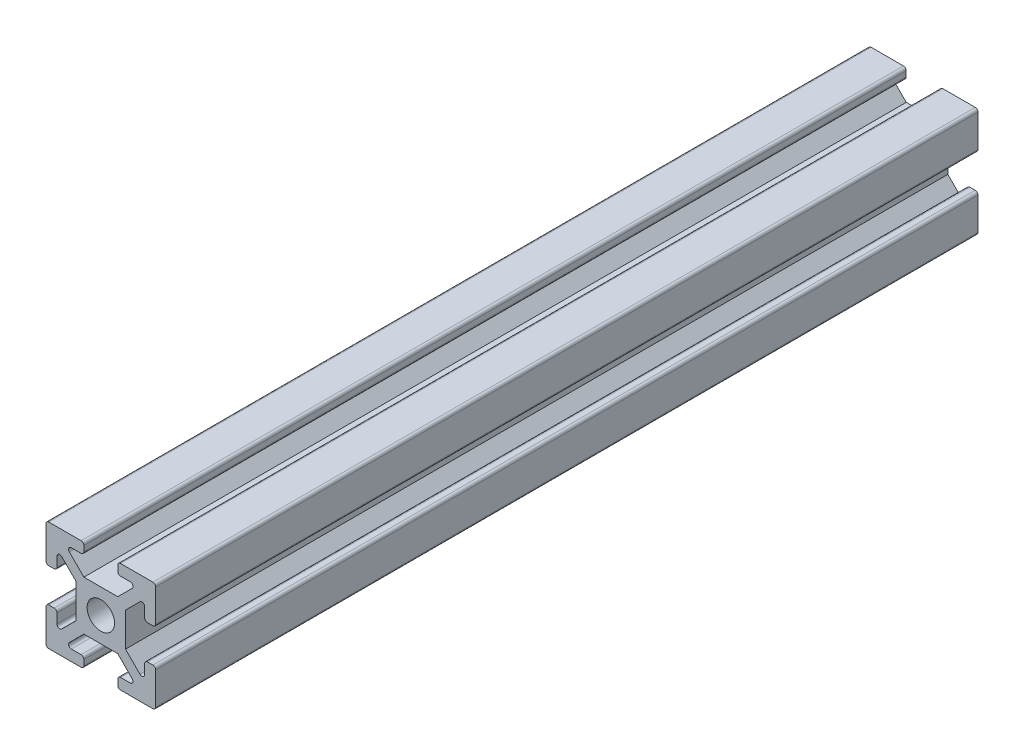
from build123d import *

# Parameters (mm, degrees)
AUFSATZ_LINEAR_AUSTRAGEN1_DEPTH = 150
VERRUNDUNG1_R                   = 0.5
KREISMUSTER1_COUNT              = 4
SKIZZE3_W                       = 9
SKIZZE3_H                       = 9
AUFSATZ_LINEAR_AUSTRAGEN2_DEPTH = 150
SKIZZE4_R                       = 2.5
SCHNITT_LINEAR_AUSTRAGEN1_DEPTH = 151


with BuildPart() as part:
    # Skizze1 → Aufsatz-Linear austragen1 (new body)
    with BuildSketch(Plane.XY):
        Polygon((-0.707106781, 0.707106781), (6.585786438, 8), (3.1, 8), (3.1, 10), (10, 10), (10, 3.1), (8, 3.1), (8, 6.585786438), (0.707106781, -0.707106781), align=None)
    extrude(amount=AUFSATZ_LINEAR_AUSTRAGEN1_DEPTH)

    # Verrundung1
    verrundung1_edges = [part.edges().sort_by_distance(p)[0] for p in [
        (10, 3.1, 75),
        (8, 3.1, 75),
        (8, 6.585786438, 75),
        (6.585786438, 8, 75),
        (3.1, 8, 75),
        (3.1, 10, 75),
        (10, 10, 75),
    ]]
    fillet(verrundung1_edges, radius=VERRUNDUNG1_R)

    # Kreismuster1: part ×4 about axis
    kreismuster1_axis = Axis((0, 0, 0), (0, 0, 1))


with BuildPart() as part_1:
    add(part.part)
    for i in range(1, KREISMUSTER1_COUNT):
        add(part.part.rotate(kreismuster1_axis, i * 360 / KREISMUSTER1_COUNT))

    # Skizze3 → Aufsatz-Linear austragen2 (add)
    with BuildSketch(Plane.XY.offset(150)):
        Rectangle(SKIZZE3_W, SKIZZE3_H)
    extrude(amount=-AUFSATZ_LINEAR_AUSTRAGEN2_DEPTH)

    # Skizze4 → Schnitt-Linear austragen1 (cut, through all)
    with BuildSketch(Plane.XY.offset(150)):
        Circle(SKIZZE4_R)
    extrude(amount=-SCHNITT_LINEAR_AUSTRAGEN1_DEPTH, mode=Mode.SUBTRACT)


solid = part_1.part
